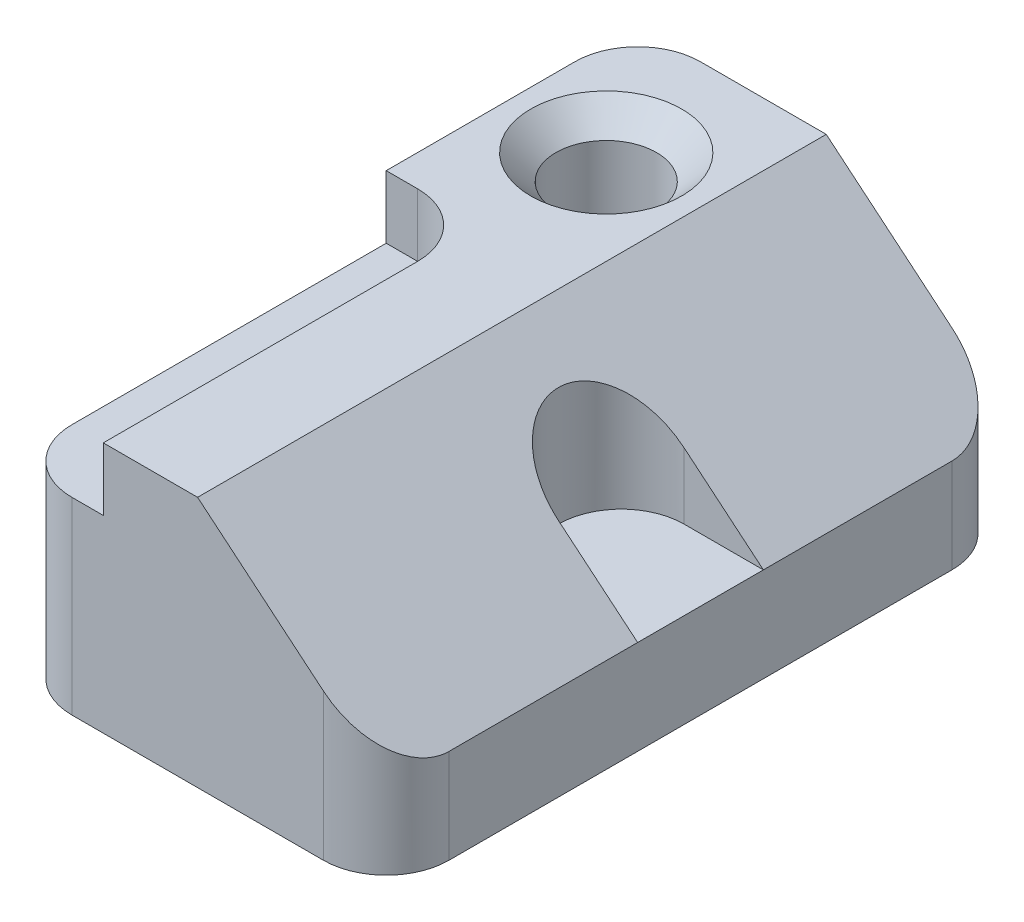
from build123d import *

# Parameters (mm, degrees)
BOSS_EXTRUDE1_DEPTH     = 127
SKETCH3_R               = 10.16
CUT_EXTRUDE1_DEPTH      = 127
CHAMFER1_SIZE           = 5.08
SKETCH4_W               = 19.05
SKETCH4_H               = 76.2
CUT_EXTRUDE3_DEPTH      = 1
CUT_EXTRUDE3_DEPTH_BACK = 12.7
FILLET1_R               = 12.7
CUT_EXTRUDE4_DEPTH      = 31.75
FILLET2_R               = 12.7
FILLET3_R               = 12.7
FILLET4_R               = 12.7
FILLET5_R               = 12.7


with BuildPart() as part:
    # Sketch1 → Boss-Extrude1 (new body)
    with BuildSketch(Plane.XY):
        Polygon((0, 0), (0, 50.8), (38.1, 50.8), (76.2, 19.05), (76.2, 0), align=None)
    extrude(amount=BOSS_EXTRUDE1_DEPTH)

    # Sketch3 → Cut-Extrude1 (cut)
    with BuildSketch(Plane(origin=(0, 50.8, 0), x_dir=(1, 0, 0), z_dir=(0, 1, 0))):
        with Locations((19.05, -25.4)):
            Circle(SKETCH3_R)
    extrude(amount=-CUT_EXTRUDE1_DEPTH, mode=Mode.SUBTRACT)

    # Chamfer1
    chamfer1_edges = [part.edges().sort_by_distance(p)[0] for p in [
        (8.89, 50.8, 25.4),
    ]]
    chamfer(chamfer1_edges, length=CHAMFER1_SIZE)

    # Sketch4 → Cut-Extrude3 (cut, two sides)
    with BuildSketch(Plane(origin=(0, 50.8, 0), x_dir=(1, 0, 0), z_dir=(0, 1, 0))) as cut_extrude3_sk:
        with Locations((9.525, -88.9)):
            Rectangle(SKETCH4_W, SKETCH4_H)
    extrude(amount=CUT_EXTRUDE3_DEPTH, mode=Mode.SUBTRACT)
    extrude(cut_extrude3_sk.sketch, amount=-CUT_EXTRUDE3_DEPTH_BACK, mode=Mode.SUBTRACT)

    # Fillet1
    fillet1_edges = [part.edges().sort_by_distance(p)[0] for p in [
        (19.05, 44.45, 50.8),
    ]]
    fillet(fillet1_edges, radius=FILLET1_R)

    # Sketch5 → Cut-Extrude4 (cut)
    with BuildSketch(Plane(origin=(0, 50.8, 0), x_dir=(1, 0, 0), z_dir=(0, 1, 0))):
        with BuildLine():
            Line((76.2, -50.8), (60.198, -50.8))
            ThreePointArc((60.198, -50.8), (47.498, -63.5), (60.198, -76.2))
            Line((60.198, -76.2), (76.2, -76.2))
            Line((76.2, -76.2), (76.2, -50.8))
        make_face()
    extrude(amount=-CUT_EXTRUDE4_DEPTH, mode=Mode.SUBTRACT)

    # Fillet2
    fillet2_edges = [part.edges().sort_by_distance(p)[0] for p in [
        (0, 19.05, 127),
    ]]
    fillet(fillet2_edges, radius=FILLET2_R)

    # Fillet3
    fillet3_edges = [part.edges().sort_by_distance(p)[0] for p in [
        (76.2, 9.525, 127),
    ]]
    fillet(fillet3_edges, radius=FILLET3_R)

    # Fillet4
    fillet4_edges = [part.edges().sort_by_distance(p)[0] for p in [
        (76.2, 9.525, 0),
    ]]
    fillet(fillet4_edges, radius=FILLET4_R)

    # Fillet5
    fillet5_edges = [part.edges().sort_by_distance(p)[0] for p in [
        (0, 25.4, 0),
    ]]
    fillet(fillet5_edges, radius=FILLET5_R)


solid = part.part
